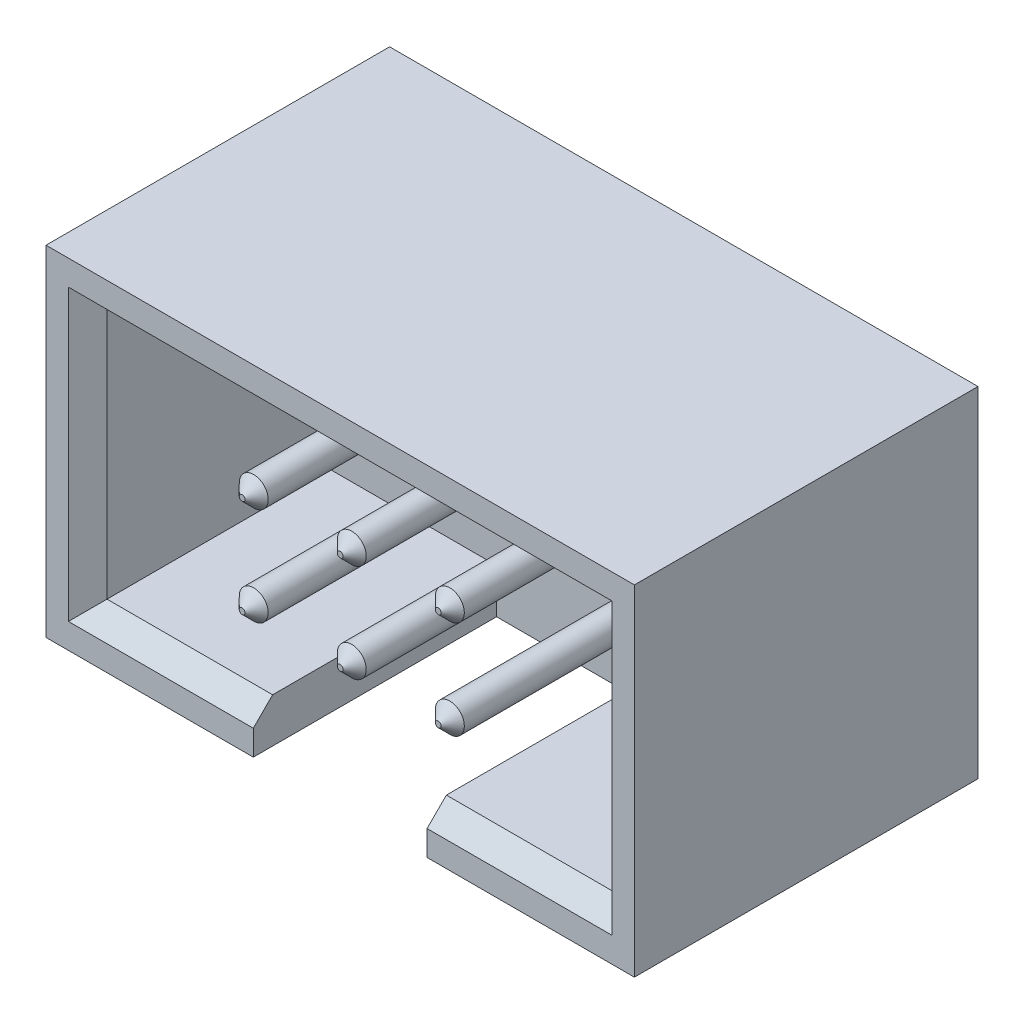
from build123d import *

# Parameters (mm, degrees)
SKETCH1_W                  = 15.24
SKETCH1_H                  = 8.8
BOSS_EXTRUDE1_DEPTH        = 2.6
BOSS_EXTRUDE2_DEPTH        = 6.3
CHAMFER1_SIZE              = 0.5
CUT_EXTRUDE1_REACH         = 4.6
SKETCH3_R                  = 0.4
SKETCH4_R                  = 0.375
BOSS_EXTRUDE3_DEPTH        = 6.3
BOSS_EXTRUDE3_DEPTH_BACK   = 5.4
BOSS_EXTRUDE3_2_DEPTH      = 6.3
BOSS_EXTRUDE3_2_DEPTH_BACK = 5.4
BOSS_EXTRUDE3_3_DEPTH      = 6.3
BOSS_EXTRUDE3_3_DEPTH_BACK = 5.4
BOSS_EXTRUDE3_4_DEPTH      = 6.3
BOSS_EXTRUDE3_4_DEPTH_BACK = 5.4
BOSS_EXTRUDE3_5_DEPTH      = 6.3
BOSS_EXTRUDE3_5_DEPTH_BACK = 5.4
BOSS_EXTRUDE3_6_DEPTH      = 6.3
BOSS_EXTRUDE3_6_DEPTH_BACK = 5.4
CHAMFER2_SIZE              = 0.3
CHAMFER3_SIZE              = 0.3
CHAMFER4_SIZE              = 0.3
CHAMFER5_SIZE              = 0.3
CHAMFER6_SIZE              = 0.3
CHAMFER7_SIZE              = 0.3
CHAMFER8_SIZE              = 0.3
CHAMFER9_SIZE              = 0.3
CHAMFER10_SIZE             = 0.3
CHAMFER11_SIZE             = 0.3
CHAMFER12_SIZE             = 0.3


with BuildPart() as part:
    # Sketch1 → Boss-Extrude1 (new body)
    with BuildSketch(Plane.XY):
        Rectangle(SKETCH1_W, SKETCH1_H)
    extrude(amount=BOSS_EXTRUDE1_DEPTH)

    # Sketch2 → Boss-Extrude2 (add)
    with BuildSketch(Plane.XY.offset(2.6)):
        Polygon((-6.54, 3.25), (6.54, 3.25), (6.54, -3.25), (2.25, -3.25), (2.25, -4.4), (7.62, -4.4), (7.62, 4.4), (-7.62, 4.4), (-7.62, -4.4), (-2.25, -4.4), (-2.25, -3.25), (-6.54, -3.25), align=None)
    extrude(amount=BOSS_EXTRUDE2_DEPTH)

    # Chamfer1
    chamfer1_edges = [part.edges().sort_by_distance(p)[0] for p in [
        (4.395, -3.25, 8.9),
        (-4.395, -3.25, 8.9),
        (-6.54, 0, 8.9),
        (0, 3.25, 8.9),
        (6.54, 0, 8.9),
    ]]
    chamfer(chamfer1_edges, length=CHAMFER1_SIZE)

    # Sketch3 → Cut-Extrude1 (cut, up to next)
    with BuildSketch(Plane.XY.offset(2.6), mode=Mode.PRIVATE) as cut_extrude1_sk1:
        with Locations((0, 1.27)):
            Circle(SKETCH3_R)
    cut_extrude1_tool1 = extrude(cut_extrude1_sk1.sketch, amount=-CUT_EXTRUDE1_REACH, mode=Mode.PRIVATE) & part.part
    add(cut_extrude1_tool1.solids().sort_by_distance((0, 1.27, 2.6))[0], mode=Mode.SUBTRACT)
    # Sketch3 → Cut-Extrude1 (cut, up to next)
    with BuildSketch(Plane.XY.offset(2.6), mode=Mode.PRIVATE) as cut_extrude1_sk2:
        with Locations((2.54, 1.27)):
            Circle(SKETCH3_R)
    cut_extrude1_tool2 = extrude(cut_extrude1_sk2.sketch, amount=-CUT_EXTRUDE1_REACH, mode=Mode.PRIVATE) & part.part
    add(cut_extrude1_tool2.solids().sort_by_distance((2.54, 1.27, 2.6))[0], mode=Mode.SUBTRACT)
    # Sketch3 → Cut-Extrude1 (cut, up to next)
    with BuildSketch(Plane.XY.offset(2.6), mode=Mode.PRIVATE) as cut_extrude1_sk3:
        with Locations((-2.54, 1.27)):
            Circle(SKETCH3_R)
    cut_extrude1_tool3 = extrude(cut_extrude1_sk3.sketch, amount=-CUT_EXTRUDE1_REACH, mode=Mode.PRIVATE) & part.part
    add(cut_extrude1_tool3.solids().sort_by_distance((-2.54, 1.27, 2.6))[0], mode=Mode.SUBTRACT)
    # Sketch3 → Cut-Extrude1 (cut, up to next)
    with BuildSketch(Plane.XY.offset(2.6), mode=Mode.PRIVATE) as cut_extrude1_sk4:
        with Locations((2.54, -1.27)):
            Circle(SKETCH3_R)
    cut_extrude1_tool4 = extrude(cut_extrude1_sk4.sketch, amount=-CUT_EXTRUDE1_REACH, mode=Mode.PRIVATE) & part.part
    add(cut_extrude1_tool4.solids().sort_by_distance((2.54, -1.27, 2.6))[0], mode=Mode.SUBTRACT)
    # Sketch3 → Cut-Extrude1 (cut, up to next)
    with BuildSketch(Plane.XY.offset(2.6), mode=Mode.PRIVATE) as cut_extrude1_sk5:
        with Locations((0, -1.27)):
            Circle(SKETCH3_R)
    cut_extrude1_tool5 = extrude(cut_extrude1_sk5.sketch, amount=-CUT_EXTRUDE1_REACH, mode=Mode.PRIVATE) & part.part
    add(cut_extrude1_tool5.solids().sort_by_distance((0, -1.27, 2.6))[0], mode=Mode.SUBTRACT)
    # Sketch3 → Cut-Extrude1 (cut, up to next)
    with BuildSketch(Plane.XY.offset(2.6), mode=Mode.PRIVATE) as cut_extrude1_sk6:
        with Locations((-2.54, -1.27)):
            Circle(SKETCH3_R)
    cut_extrude1_tool6 = extrude(cut_extrude1_sk6.sketch, amount=-CUT_EXTRUDE1_REACH, mode=Mode.PRIVATE) & part.part
    add(cut_extrude1_tool6.solids().sort_by_distance((-2.54, -1.27, 2.6))[0], mode=Mode.SUBTRACT)


with BuildPart() as body_2:
    # Sketch4 → Boss-Extrude3 (new body, two sides)
    with BuildSketch(Plane.XY.offset(2.6)) as boss_extrude3_sk:
        with Locations((-2.54, 1.27)):
            Circle(SKETCH4_R)
    extrude(amount=BOSS_EXTRUDE3_DEPTH)
    extrude(boss_extrude3_sk.sketch, amount=-BOSS_EXTRUDE3_DEPTH_BACK)

    # Chamfer8
    chamfer8_edges = [body_2.edges().sort_by_distance(p)[0] for p in [
        (-2.915, 1.27, -2.8),
    ]]
    chamfer(chamfer8_edges, length=CHAMFER8_SIZE)

    # Chamfer12
    chamfer12_edges = [body_2.edges().sort_by_distance(p)[0] for p in [
        (-2.915, 1.27, 8.9),
    ]]
    chamfer(chamfer12_edges, length=CHAMFER12_SIZE)


with BuildPart() as body_3:
    # Sketch4 → Boss-Extrude3 2 (new body, two sides)
    with BuildSketch(Plane.XY.offset(2.6)) as boss_extrude3_2_sk:
        with Locations((0, 1.27)):
            Circle(SKETCH4_R)
    extrude(amount=BOSS_EXTRUDE3_2_DEPTH)
    extrude(boss_extrude3_2_sk.sketch, amount=-BOSS_EXTRUDE3_2_DEPTH_BACK)

    # Chamfer7
    chamfer7_edges = [body_3.edges().sort_by_distance(p)[0] for p in [
        (-0.375, 1.27, -2.8),
    ]]
    chamfer(chamfer7_edges, length=CHAMFER7_SIZE)

    # Chamfer11
    chamfer11_edges = [body_3.edges().sort_by_distance(p)[0] for p in [
        (-0.375, 1.27, 8.9),
    ]]
    chamfer(chamfer11_edges, length=CHAMFER11_SIZE)


with BuildPart() as body_4:
    # Sketch4 → Boss-Extrude3 3 (new body, two sides)
    with BuildSketch(Plane.XY.offset(2.6)) as boss_extrude3_3_sk:
        with Locations((2.54, 1.27)):
            Circle(SKETCH4_R)
    extrude(amount=BOSS_EXTRUDE3_3_DEPTH)
    extrude(boss_extrude3_3_sk.sketch, amount=-BOSS_EXTRUDE3_3_DEPTH_BACK)

    # Chamfer6
    chamfer6_edges = [body_4.edges().sort_by_distance(p)[0] for p in [
        (2.165, 1.27, -2.8),
    ]]
    chamfer(chamfer6_edges, length=CHAMFER6_SIZE)

    # Chamfer10
    chamfer10_edges = [body_4.edges().sort_by_distance(p)[0] for p in [
        (2.165, 1.27, 8.9),
    ]]
    chamfer(chamfer10_edges, length=CHAMFER10_SIZE)


with BuildPart() as body_5:
    # Sketch4 → Boss-Extrude3 4 (new body, two sides)
    with BuildSketch(Plane.XY.offset(2.6)) as boss_extrude3_4_sk:
        with Locations((-2.54, -1.27)):
            Circle(SKETCH4_R)
    extrude(amount=BOSS_EXTRUDE3_4_DEPTH)
    extrude(boss_extrude3_4_sk.sketch, amount=-BOSS_EXTRUDE3_4_DEPTH_BACK)

    # Chamfer2
    chamfer2_edges = [body_5.edges().sort_by_distance(p)[0] for p in [
        (-2.915, -1.27, 8.9),
    ]]
    chamfer(chamfer2_edges, length=CHAMFER2_SIZE)

    # Chamfer3
    chamfer3_edges = [body_5.edges().sort_by_distance(p)[0] for p in [
        (-2.915, -1.27, -2.8),
    ]]
    chamfer(chamfer3_edges, length=CHAMFER3_SIZE)


with BuildPart() as body_6:
    # Sketch4 → Boss-Extrude3 5 (new body, two sides)
    with BuildSketch(Plane.XY.offset(2.6)) as boss_extrude3_5_sk:
        with Locations((0, -1.27)):
            Circle(SKETCH4_R)
    extrude(amount=BOSS_EXTRUDE3_5_DEPTH)
    extrude(boss_extrude3_5_sk.sketch, amount=-BOSS_EXTRUDE3_5_DEPTH_BACK)

    # Chamfer4
    chamfer4_edges = [body_6.edges().sort_by_distance(p)[0] for p in [
        (-0.375, -1.27, -2.8),
    ]]
    chamfer(chamfer4_edges, length=CHAMFER4_SIZE)

    # Chamfer9
    chamfer9_edges = [body_6.edges().sort_by_distance(p)[0] for p in [
        (-0.375, -1.27, 8.9),
    ]]
    chamfer(chamfer9_edges, length=CHAMFER9_SIZE)


with BuildPart() as body_7:
    # Sketch4 → Boss-Extrude3 6 (new body, two sides)
    with BuildSketch(Plane.XY.offset(2.6)) as boss_extrude3_6_sk:
        with Locations((2.54, -1.27)):
            Circle(SKETCH4_R)
    extrude(amount=BOSS_EXTRUDE3_6_DEPTH)
    extrude(boss_extrude3_6_sk.sketch, amount=-BOSS_EXTRUDE3_6_DEPTH_BACK)

    # Chamfer5
    chamfer5_edges = [body_7.edges().sort_by_distance(p)[0] for p in [
        (2.165, -1.27, 8.9),
        (2.165, -1.27, -2.8),
    ]]
    chamfer(chamfer5_edges, length=CHAMFER5_SIZE)


solid = Compound([part.part, body_2.part, body_3.part, body_4.part, body_5.part, body_6.part, body_7.part])
